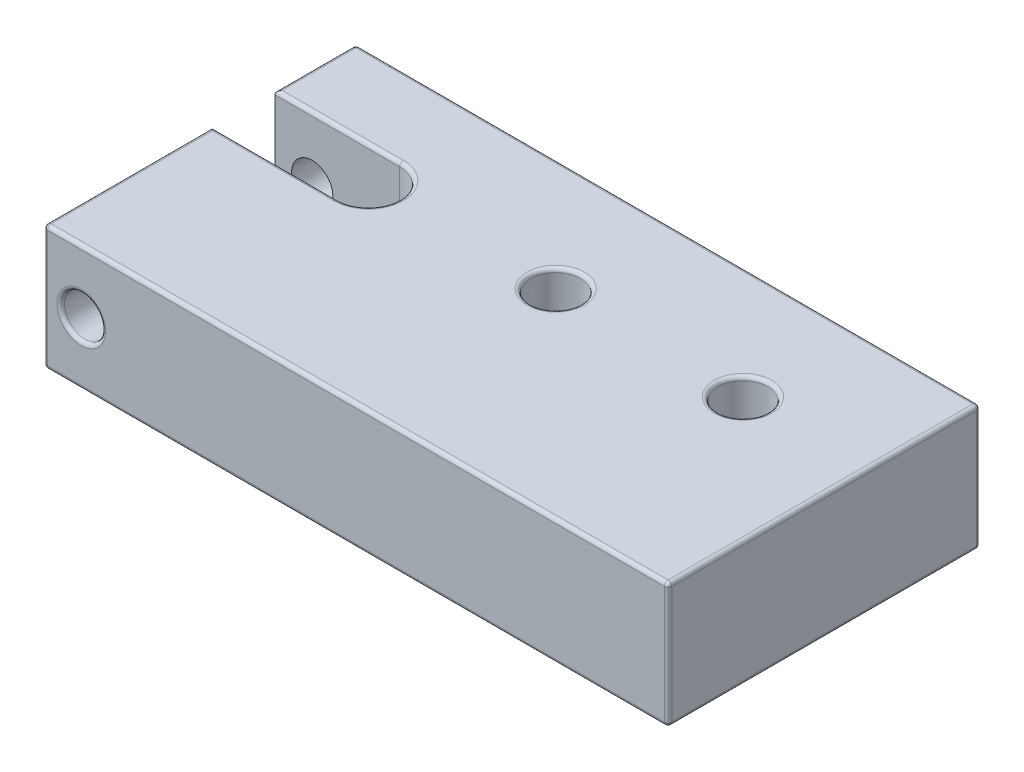
from build123d import *

# Parameters (mm, degrees)
BOSS_EXTRUDE1_DEPTH = 10
SKETCH2_R           = 2
CUT_EXTRUDE1_DEPTH  = 11
SKETCH3_R           = 1.65
CUT_EXTRUDE2_DEPTH  = 26
FILLET1_R           = 0.3


with BuildPart() as part:
    # Sketch1 → Boss-Extrude1 (new body)
    with BuildSketch(Plane(origin=(0, 0, 0), x_dir=(1, 0, 0), z_dir=(0, 1, 0))):
        with BuildLine():
            Line((0, 0), (50, 0))
            Line((50, 0), (50, 25))
            Line((50, 25), (0, 25))
            Line((0, 25), (0, 18.5))
            Line((0, 18.5), (10, 18.5))
            ThreePointArc((10, 18.5), (12.5, 16), (10, 13.5))
            Line((10, 13.5), (0, 13.5))
            Line((0, 13.5), (0, 0))
        make_face()
    extrude(amount=BOSS_EXTRUDE1_DEPTH)

    # Sketch2 → Cut-Extrude1 (cut, through all)
    with BuildSketch(Plane(origin=(0, 10, 0), x_dir=(1, 0, 0), z_dir=(0, 1, 0))):
        with Locations((40, 16)):
            Circle(SKETCH2_R)
        with Locations((25, 16)):
            Circle(SKETCH2_R)
    extrude(amount=-CUT_EXTRUDE1_DEPTH, mode=Mode.SUBTRACT)

    # Sketch3 → Cut-Extrude2 (cut, through all)
    with BuildSketch(Plane.XY):
        with Locations((3, 5)):
            Circle(SKETCH3_R)
    extrude(amount=-CUT_EXTRUDE2_DEPTH, mode=Mode.SUBTRACT)

    # Fillet1
    fillet1_edges = [part.edges().sort_by_distance(p)[0] for p in [
        (25, 0, -25),
        (50, 0, -12.5),
        (25, 0, 0),
        (0, 0, -6.75),
        (50, 10, -12.5),
        (0, 5, -25),
        (50, 5, -25),
        (50, 5, 0),
        (0, 5, 0),
        (25, 10, -25),
        (0, 10, -21.75),
        (5, 10, -18.5),
        (38, 0, -16),
        (12.5, 10, -16),
        (38, 10, -16),
        (23, 0, -16),
        (23, 10, -16),
        (5, 10, -13.5),
        (1.35, 5, -25),
        (1.35, 5, 0),
        (0, 10, -6.75),
        (5, 0, -13.5),
        (25, 10, 0),
        (12.5, 0, -16),
        (5, 0, -18.5),
        (0, 0, -21.75),
    ]]
    fillet(fillet1_edges, radius=FILLET1_R)


solid = part.part
